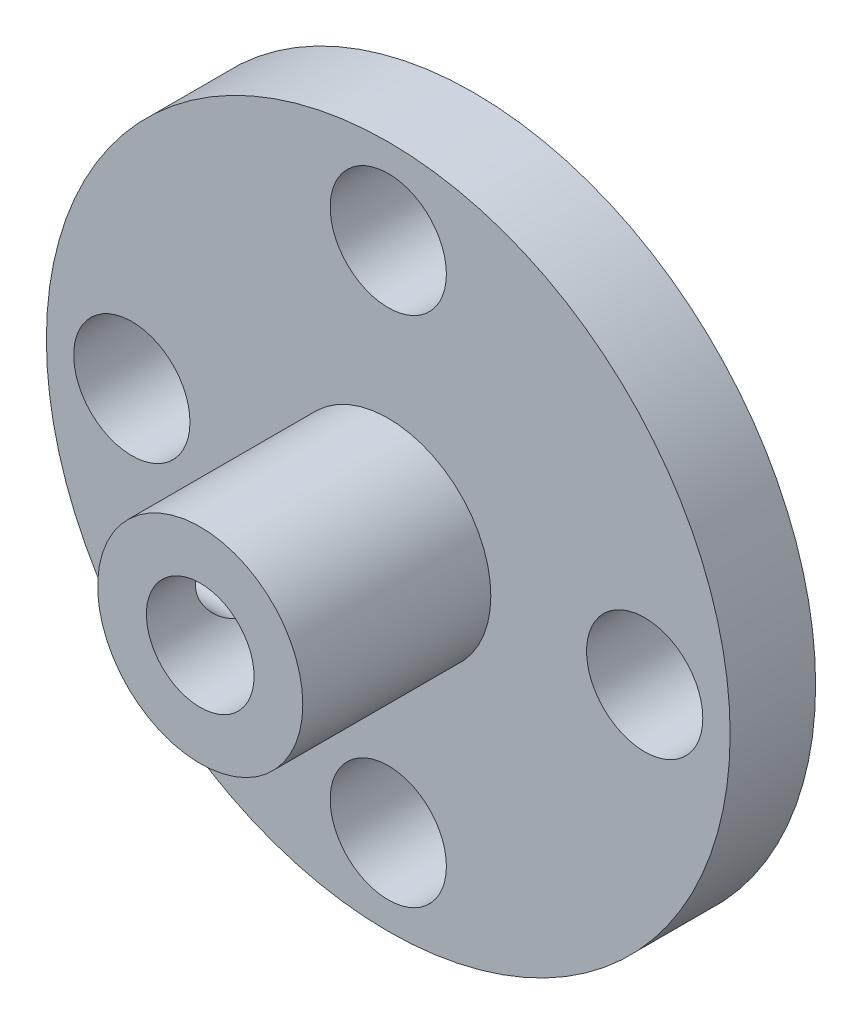
from build123d import *

# Parameters (mm, degrees)
SKETCH2_R           = 12.7
SKETCH2_R_2         = 3.81
SKETCH2_R_3         = 2.159
BOSS_EXTRUDE1_DEPTH = 3.175
SKETCH2_3_R         = 3.81
SKETCH2_3_R_2       = 2
BOSS_EXTRUDE2_DEPTH = 10.16
SKETCH4_R           = 1.35
CUT_EXTRUDE1_DEPTH  = 12.7


with BuildPart() as part:
    # Sketch2 → Boss-Extrude1 (new body)
    with BuildSketch(Plane.XY):
        Circle(SKETCH2_R)
        Circle(SKETCH2_R_2, mode=Mode.SUBTRACT)
        with Locations((0, 9.525)):
            Circle(SKETCH2_R_3, mode=Mode.SUBTRACT)
        with Locations((9.525, 0)):
            Circle(SKETCH2_R_3, mode=Mode.SUBTRACT)
        with Locations((0, -9.525)):
            Circle(SKETCH2_R_3, mode=Mode.SUBTRACT)
        with Locations((-9.525, 0)):
            Circle(SKETCH2_R_3, mode=Mode.SUBTRACT)
    extrude(amount=BOSS_EXTRUDE1_DEPTH)

    # Sketch2_3 → Boss-Extrude2 (add)
    with BuildSketch(Plane.XY):
        Circle(SKETCH2_3_R)
        Circle(SKETCH2_3_R_2, mode=Mode.SUBTRACT)
    extrude(amount=BOSS_EXTRUDE2_DEPTH)

    # Sketch4 → Cut-Extrude1 (cut)
    with BuildSketch(Plane(origin=(0, 0, 0), x_dir=(0, 0, -1), z_dir=(1, 0, 0))):
        with Locations((-6.985, 0)):
            Circle(SKETCH4_R)
    extrude(amount=-CUT_EXTRUDE1_DEPTH, mode=Mode.SUBTRACT)


solid = part.part
